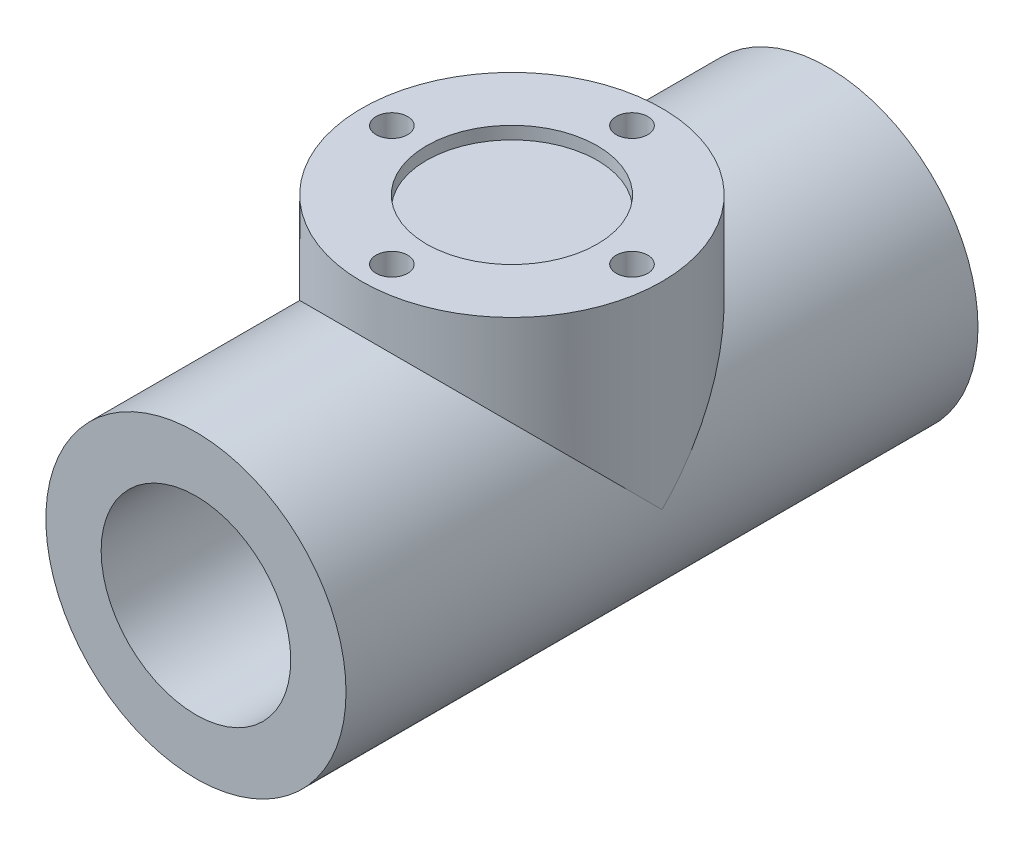
from build123d import *

# Parameters (mm, degrees)
SKETCH1_R           = 47.5
BOSS_EXTRUDE1_DEPTH = 100
SKETCH2_R           = 47.5
BOSS_EXTRUDE2_DEPTH = 62.5
SKETCH3_R           = 27
CUT_EXTRUDE1_DEPTH  = 4
HOLE1_D             = 10
HOLE1_DEPTH         = 20
SKETCH6_R           = 30
CUT_EXTRUDE2_DEPTH  = 200


with BuildPart() as part:
    # Sketch1 → Boss-Extrude1 (new body, symmetric)
    with BuildSketch(Plane.XY):
        Circle(SKETCH1_R)
    extrude(amount=BOSS_EXTRUDE1_DEPTH, both=True)

    # Sketch2 → Boss-Extrude2 (add)
    with BuildSketch(Plane(origin=(0, 0, 0), x_dir=(1, 0, 0), z_dir=(0, 1, 0))):
        Circle(SKETCH2_R)
    extrude(amount=BOSS_EXTRUDE2_DEPTH)

    # Sketch3 → Cut-Extrude1 (cut)
    with BuildSketch(Plane(origin=(0, 62.5, 0), x_dir=(1, 0, 0), z_dir=(0, 1, 0))):
        Circle(SKETCH3_R)
    extrude(amount=-CUT_EXTRUDE1_DEPTH, mode=Mode.SUBTRACT)

    # Hole1
    with Locations(Plane(origin=(38, 62.5, 0), x_dir=(0, 0, 1), z_dir=(0, 1, 0))):
        with Locations((0, 0), (-38, -38), (0, -76), (38, -38)):
            Hole(HOLE1_D / 2, depth=HOLE1_DEPTH)

    # Sketch6 → Cut-Extrude2 (cut)
    with BuildSketch(Plane(origin=(0, 0, -100), x_dir=(-1, 0, 0), z_dir=(0, 0, -1))):
        Circle(SKETCH6_R)
    extrude(amount=-CUT_EXTRUDE2_DEPTH, mode=Mode.SUBTRACT)


solid = part.part
